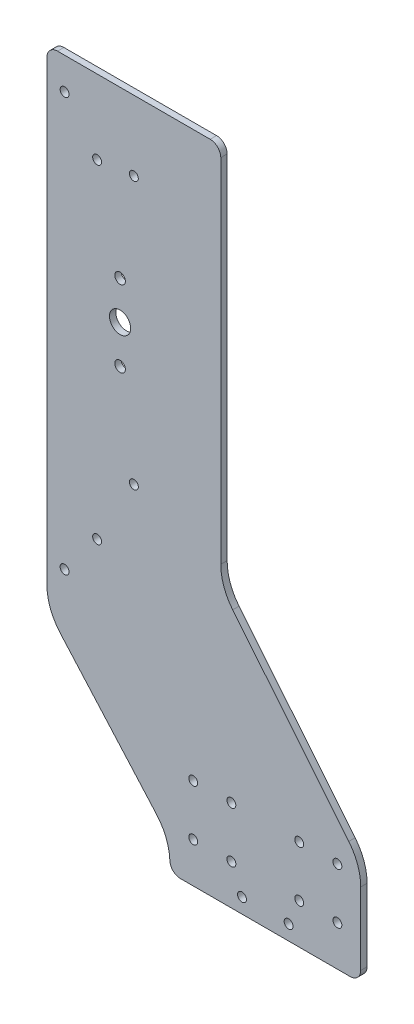
from build123d import *

# Parameters (mm, degrees)
SKETCH1_R           = 2.1
SKETCH1_R_2         = 2.5
SKETCH1_R_3         = 5
BOSS_EXTRUDE1_DEPTH = 1.5


with BuildPart() as part:
    # Sketch1 → Boss-Extrude1 (new body, symmetric)
    with BuildSketch(Plane.XY):
        with BuildLine():
            Line((107, -145), (107, -110.895624471))
            ThreePointArc((107, -110.895624471), (105.553363517, -102.514749396), (101.380874638, -95.103800692))
            Line((101.380874638, -95.103800692), (46.619125362, -27.896199308))
            ThreePointArc((46.619125362, -27.896199308), (42.446636483, -20.485250604), (41, -12.104375529))
            Line((41, -12.104375529), (41, 154))
            ThreePointArc((41, 154), (39.535533906, 157.535533906), (36, 159))
            Line((36, 159), (-36, 159))
            ThreePointArc((-36, 159), (-39.535533906, 157.535533906), (-41, 154))
            Line((-41, 154), (-41, -61.522167809))
            ThreePointArc((-41, -61.522167809), (-39.376465331, -70.384496434), (-34.716730508, -78.095761236))
            Line((-34.716730508, -78.095761236), (10.716730508, -129.404238764))
            ThreePointArc((10.716730508, -129.404238764), (15.198642313, -136.659946441), (16.980869565, -145))
            ThreePointArc((16.980869565, -145), (18.445335659, -148.535533906), (21.980869565, -150))
            Line((21.980869565, -150), (102, -150))
            ThreePointArc((102, -150), (105.535533906, -148.535533906), (107, -145))
        make_face()
        with Locations((96, -107)):
            Circle(SKETCH1_R, mode=Mode.SUBTRACT)
        with Locations((96, -131)):
            Circle(SKETCH1_R, mode=Mode.SUBTRACT)
        with Locations((78, -107)):
            Circle(SKETCH1_R, mode=Mode.SUBTRACT)
        with Locations((78, -131)):
            Circle(SKETCH1_R, mode=Mode.SUBTRACT)
        with Locations((46, -107)):
            Circle(SKETCH1_R, mode=Mode.SUBTRACT)
        with Locations((46, -131)):
            Circle(SKETCH1_R, mode=Mode.SUBTRACT)
        with Locations((28, -107)):
            Circle(SKETCH1_R, mode=Mode.SUBTRACT)
        with Locations((28, -131)):
            Circle(SKETCH1_R, mode=Mode.SUBTRACT)
        with Locations((-6.5, 81)):
            Circle(SKETCH1_R_2, mode=Mode.SUBTRACT)
        with Locations((-6.5, 45)):
            Circle(SKETCH1_R_2, mode=Mode.SUBTRACT)
        with Locations((-6.5, 63)):
            Circle(SKETCH1_R_3, mode=Mode.SUBTRACT)
        with Locations((51, -143)):
            Circle(SKETCH1_R, mode=Mode.SUBTRACT)
        with Locations((73, -143)):
            Circle(SKETCH1_R, mode=Mode.SUBTRACT)
        with Locations((0, 126)):
            Circle(SKETCH1_R, mode=Mode.SUBTRACT)
        Circle(SKETCH1_R, mode=Mode.SUBTRACT)
        with Locations((-32.666666667, 144)):
            Circle(SKETCH1_R, mode=Mode.SUBTRACT)
        with Locations((-17.333333333, 124)):
            Circle(SKETCH1_R, mode=Mode.SUBTRACT)
        with Locations((-17.333333333, -31)):
            Circle(SKETCH1_R, mode=Mode.SUBTRACT)
        with Locations((-32.666666667, -51)):
            Circle(SKETCH1_R, mode=Mode.SUBTRACT)
    extrude(amount=BOSS_EXTRUDE1_DEPTH, both=True)


solid = part.part
